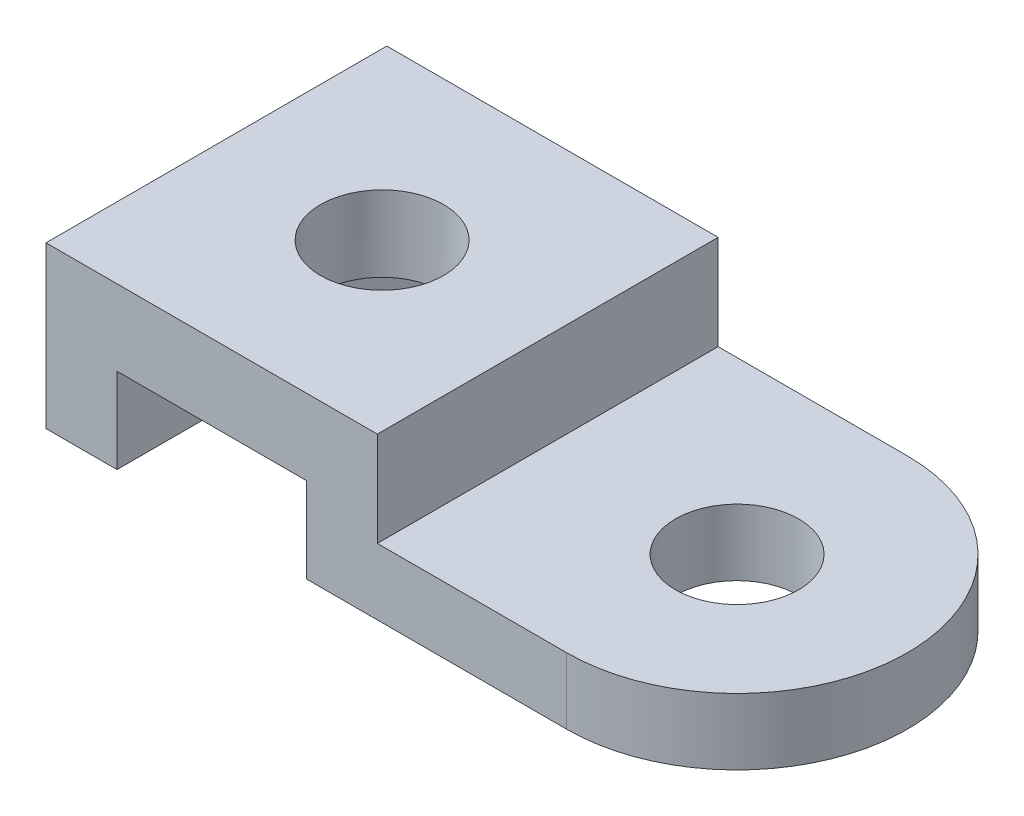
from build123d import *

# Parameters (mm, degrees)
IZIM2_R                     = 13
IZIM2_W                     = 70
IZIM2_H                     = 72
Y_KSEKLIK_EKSTR_ZYON1_DEPTH = 34
IZIM3_OUTSIDE_W             = 181.26
IZIM3_OUTSIDE_H             = 69.26
KES_EKSTR_ZYON4_DEPTH       = 73


with BuildPart() as part:
    # Çizim2 → Yükseklik-Ekstrüzyon1 (new body)
    with BuildSketch(Plane(origin=(0, 0, 0), x_dir=(1, 0, 0), z_dir=(0, 1, 0))):
        with BuildLine():
            Line((35, 36), (35, -36))
            Line((35, -36), (75, -36))
            ThreePointArc((75, -36), (111, 0), (75, 36))
            Line((75, 36), (35, 36))
        make_face()
        with Locations((75, 0)):
            Circle(IZIM2_R, mode=Mode.SUBTRACT)
        Rectangle(IZIM2_W, IZIM2_H)
        Circle(IZIM2_R, mode=Mode.SUBTRACT)
    extrude(amount=-Y_KSEKLIK_EKSTR_ZYON1_DEPTH)

    # Çizim3 outside → Kes-Ekstrüzyon4 (cut, through all)
    with BuildSketch(Plane.XY.offset(36)):
        with Locations((38, -17)):
            Rectangle(IZIM3_OUTSIDE_W, IZIM3_OUTSIDE_H)
        Polygon((-35, 0), (-35, -34), (-20, -34), (-20, -16), (20, -16), (20, -34), (75, -34), (111, -34), (111, -20), (75, -20), (35, -20), (35, 0), align=None, mode=Mode.SUBTRACT)
    extrude(amount=-KES_EKSTR_ZYON4_DEPTH, mode=Mode.SUBTRACT)


solid = part.part
